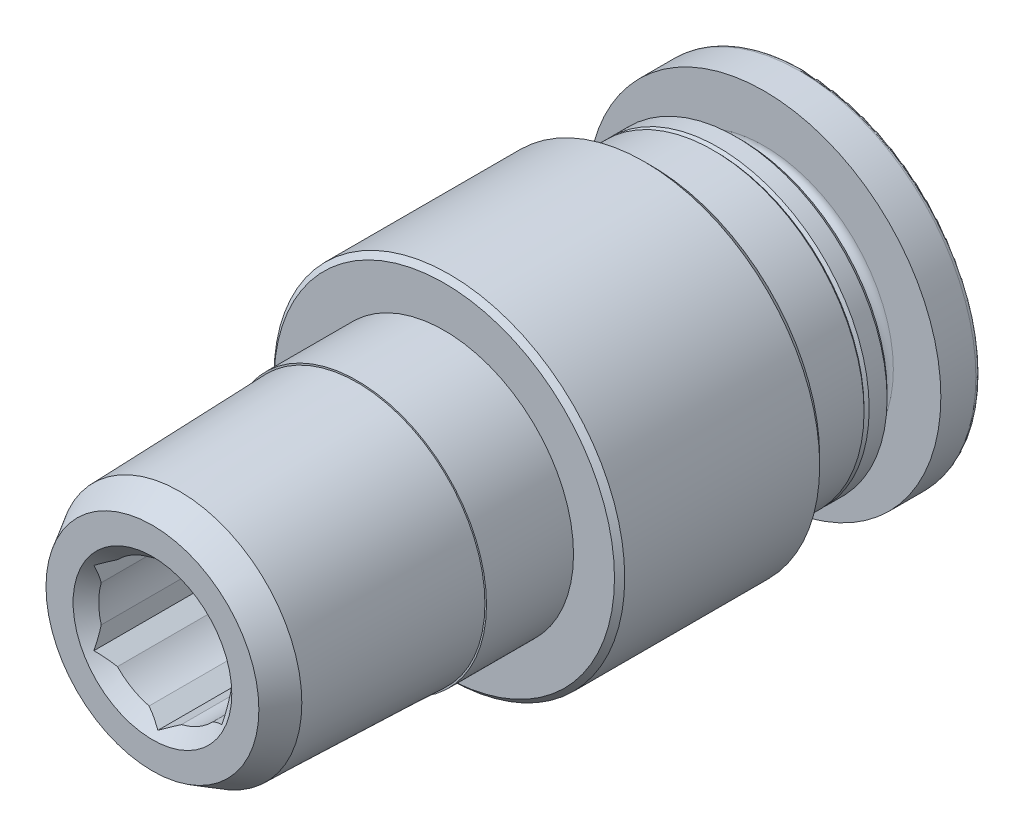
from build123d import *

# Parameters (mm, degrees)
CUT_EXTRUDE1_DEPTH = 7.7


with BuildPart() as part:
    # Sketch1 → Revolve1 (revolve)
    with BuildSketch(Plane(origin=(0, 0, 0), x_dir=(0, 0, -1), z_dir=(1, 0, 0))):
        with BuildLine():
            Line((0, 0), (0, 6.85))
            Line((0, 6.85), (11.217157288, 6.85))
            Line((11.217157288, 6.85), (11.5, 6.567157288))
            Line((11.5, 6.567157288), (11.5, 5.9))
            Line((11.5, 5.9), (13.9, 5.9))
            Line((13.9, 5.9), (14, 5.8))
            Line((14, 5.8), (14.1, 5.9))
            Line((14.1, 5.9), (14.8, 5.9))
            Line((14.8, 5.9), (15, 5.7))
            Line((15, 5.7), (15, 4.669))
            Line((15, 4.669), (15.525, 4.669))
            ThreePointArc((15.525, 4.669), (15.790165043, 4.778834957), (15.9, 5.044))
            Line((15.9, 5.044), (15.9, 6.9))
            Line((15.9, 6.9), (17.268263788, 6.9))
            ThreePointArc((17.268263788, 6.9), (17.396821309, 6.853208889), (17.465225338, 6.734729636))
            Line((17.465225338, 6.734729636), (17.9, 4.269))
            Line((17.9, 4.269), (17.9, 0))
            Line((17.9, 0), (0, 0))
        make_face()
    revolve(axis=Axis((0, 0, -17.9), (0, 0, 1)))

    # Sketch2 → Revolve2 (revolve)
    with BuildSketch(Plane(origin=(0, 0, 0), x_dir=(0, 0, -1), z_dir=(1, 0, 0))):
        Polygon((-8, 0), (-8, 4.158121832), (-6.93615215, 4.772334675), (0, 4.988878168), (0, 0), align=None)
    revolve(axis=Axis((0, 0, 0), (0, 0, 1)))

    # Sketch3 → Cut-Revolve1 (revolve, cut)
    with BuildSketch(Plane(origin=(0, 0, 0), x_dir=(0, 0, -1), z_dir=(1, 0, 0))):
        Polygon((0, 6.85), (0, 5.05), (3.4, 5.05), (3.4, 6.65), (3.6, 6.85), align=None)
    revolve(axis=Axis((0, 0, -50), (0, 0, 1)), mode=Mode.SUBTRACT)

    # Sketch4 → Cut-Revolve2 (revolve, cut)
    with BuildSketch(Plane(origin=(0, 0, 0), x_dir=(0, 0, -1), z_dir=(1, 0, 0))):
        with BuildLine():
            Line((-8, 0), (-8, 3.1))
            Line((-8, 3.1), (-7.5, 2.6))
            Line((-7.5, 2.6), (-0.3, 2.6))
            Line((-0.3, 2.6), (-0.3, 3.969))
            Line((-0.3, 3.969), (17.6, 3.969))
            ThreePointArc((17.6, 3.969), (17.812132034, 4.056867966), (17.9, 4.269))
            Line((17.9, 4.269), (17.9, 0))
            Line((17.9, 0), (-8, 0))
        make_face()
    revolve(axis=Axis((0, 0, -17.9), (0, 0, 1)), mode=Mode.SUBTRACT)

    # Sketch5 → Cut-Extrude1 (cut)
    with BuildSketch(Plane.XY.offset(0.3)):
        Polygon((-2.5, -1.443375673), (0, -2.886751346), (2.5, -1.443375673), (2.5, 1.443375673), (0, 2.886751346), (-2.5, 1.443375673), align=None)
    extrude(amount=CUT_EXTRUDE1_DEPTH, mode=Mode.SUBTRACT)


solid = part.part
